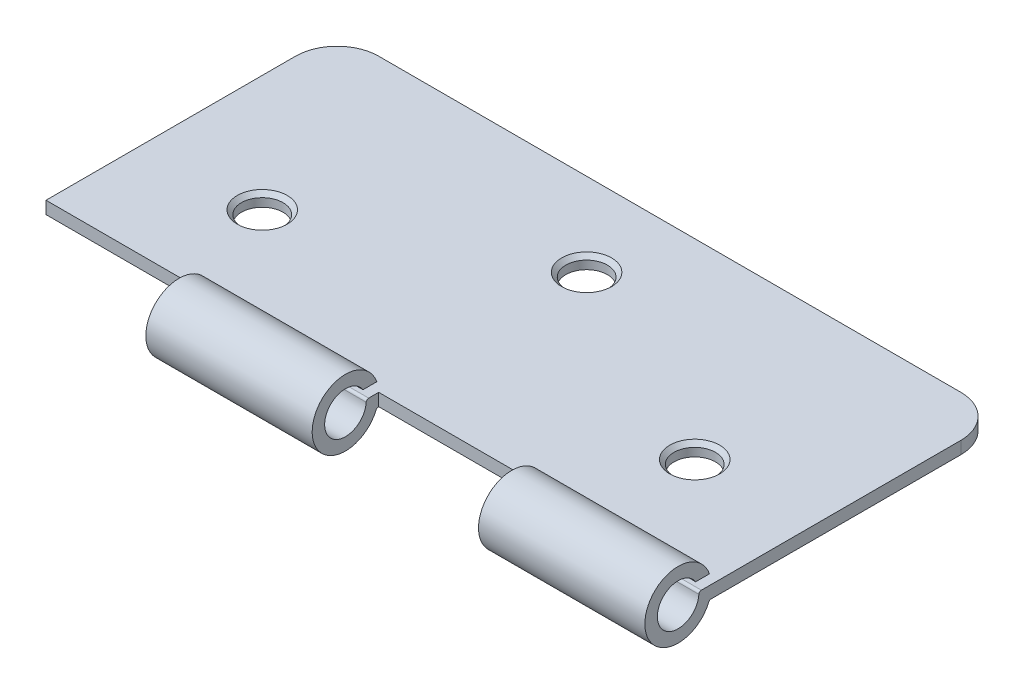
from build123d import *

# Parameters (mm, degrees)
BOSS_EXTRUDE1_DEPTH = 1.5
BOSS_EXTRUDE2_DEPTH = 20
LPATTERN1_COUNT     = 2
LPATTERN1_PITCH     = 40
SKETCH4_R           = 2.5
CUT_EXTRUDE1_DEPTH  = 5.124819455
CHAMFER1_SIZE       = 0.5


with BuildPart() as part:
    # Sketch1 → Boss-Extrude1 (new body)
    with BuildSketch(Plane(origin=(0, 0, 0), x_dir=(1, 0, 0), z_dir=(0, 1, 0))):
        with BuildLine():
            Line((40, -17.5), (-40, -17.5))
            Line((-40, -17.5), (-40, 12.5))
            ThreePointArc((-40, 12.5), (-38.535533906, 16.035533906), (-35, 17.5))
            Line((-35, 17.5), (35, 17.5))
            ThreePointArc((35, 17.5), (38.535533906, 16.035533906), (40, 12.5))
            Line((40, 12.5), (40, -17.5))
        make_face()
    extrude(amount=BOSS_EXTRUDE1_DEPTH)

    # Sketch3 → Boss-Extrude2 (add)
    with BuildSketch(Plane(origin=(40, 0, 0), x_dir=(0, 0, -1), z_dir=(1, 0, 0))):
        with BuildLine():
            Line((-19.385927186, 2.712688903), (-17.728294567, 2.712688903))
            ThreePointArc((-17.728294567, 2.712688903), (-25.49630848, 1.493271308), (-17.813805195, -0.182486041))
            ThreePointArc((-17.813805195, -0.182486041), (-17.700741006, -0.047620698), (-17.531495251, 0.000629131))
            Line((-17.531495251, 0.000629131), (-17.5, 0))
            Line((-17.5, 0), (-17.5, 1.5))
            Line((-17.5, 1.5), (-18.703537452, 1.5))
            ThreePointArc((-18.703537452, 1.5), (-18.908926347, 1.418667331), (-19.002949729, 1.218769344))
            ThreePointArc((-19.002949729, 1.218769344), (-23.919742449, 0.754362088), (-19.385927186, 2.712688903))
        make_face()
    boss_extrude2 = extrude(amount=-BOSS_EXTRUDE2_DEPTH)

    # LPattern1: Boss-Extrude2 ×2
    with Locations(*[(-i * LPATTERN1_PITCH, 0, 0) for i in range(1, LPATTERN1_COUNT)]):
        add(boss_extrude2)

    # Sketch4 → Cut-Extrude1 (cut, through all)
    with BuildSketch(Plane(origin=(0, 1.5, 0), x_dir=(1, 0, 0), z_dir=(0, 1, 0))):
        with Locations((0, 7.5)):
            Circle(SKETCH4_R)
        with Locations((-26, -5.5)):
            Circle(SKETCH4_R)
        with Locations((26, -5.5)):
            Circle(SKETCH4_R)
    extrude(amount=-CUT_EXTRUDE1_DEPTH, mode=Mode.SUBTRACT)

    # Chamfer1
    chamfer1_edges = [part.edges().sort_by_distance(p)[0] for p in [
        (-2.5, 1.5, -7.5),
        (-28.5, 1.5, 5.5),
        (23.5, 1.5, 5.5),
    ]]
    chamfer(chamfer1_edges, length=CHAMFER1_SIZE)


solid = part.part
